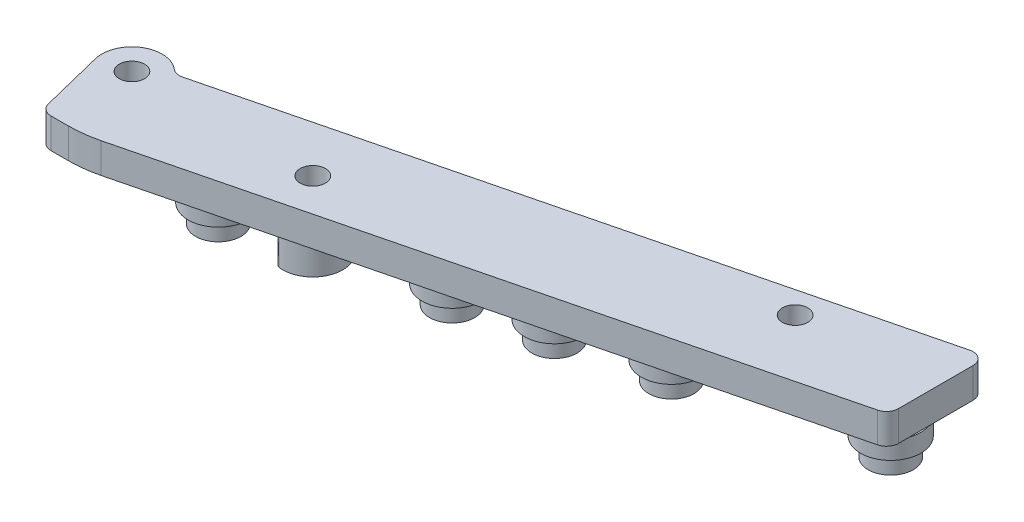
from build123d import *

# Parameters (mm, degrees)
SKETCH1_R           = 2.667
BOSS_EXTRUDE1_DEPTH = 6.35
SKETCH3_R           = 6.35
BOSS_EXTRUDE2_DEPTH = 3.81
SKETCH4_R           = 4.7625
BOSS_EXTRUDE3_DEPTH = 3.81
SKETCH5_R           = 6.35
SKETCH5_R_2         = 2.667
SKETCH5_R_3         = 5.08
SKETCH5_R_4         = 2.723974981
BOSS_EXTRUDE4_DEPTH = 7.62


with BuildPart() as part:
    # Sketch1 → Boss-Extrude1 (new body)
    with BuildSketch(Plane(origin=(0, 0, 0), x_dir=(-1, 0, 0), z_dir=(0, 1, 0))):
        with BuildLine():
            Line((132.859114436, 54.06756661), (1.925518385, 21.422154602))
            ThreePointArc((1.925518385, 21.422154602), (0.538452686, 20.521383604), (0, 18.957603457))
            Line((0, 18.957603457), (0, 3.251051746))
            ThreePointArc((0, 3.251051746), (0.976219853, 1.249504432), (3.154481615, 0.786500601))
            Line((3.154481615, 0.786500601), (135.868185597, 33.875743365))
            ThreePointArc((135.868185597, 33.875743365), (137.061865325, 33.884273202), (138.127619437, 33.346581632))
            ThreePointArc((138.127619437, 33.346581632), (145.587943549, 32.789337046), (148.401377862, 39.7212592))
            Line((148.401377862, 39.7212592), (145.116412217, 52.896536778))
            ThreePointArc((145.116412217, 52.896536778), (144.215641219, 54.283602477), (142.651861072, 54.822055163))
            Line((142.651861072, 54.822055163), (139.003930584, 54.822055163))
            ThreePointArc((139.003930584, 54.822055163), (135.908449262, 54.632727414), (132.859114436, 54.06756661))
        make_face()
        with Locations(Location((142.24, 38.185055163, 0), (0, 0, 90))):
            Circle(SKETCH1_R, mode=Mode.SUBTRACT)
        with Locations(Location((27.94, 12.785055202, 0), (0, 0, 90))):
            Circle(SKETCH1_R, mode=Mode.SUBTRACT)
        with Locations(Location((104.14, 38.185055202, 0), (0, 0, 90))):
            Circle(SKETCH1_R, mode=Mode.SUBTRACT)
    extrude(amount=-BOSS_EXTRUDE1_DEPTH)

    # Sketch3 → Boss-Extrude2 (add)
    with BuildSketch(Plane(origin=(0, -6.35, 0), x_dir=(-1, 0, 0), z_dir=(0, -1, 0))):
        with Locations(Location((6.00871488, -14.586933973, 0), (0, 0, 198.870092131))):
            Circle(SKETCH3_R)
        with Locations(Location((42.976982051, -23.804158196, 0), (0, 0, 270))):
            Circle(SKETCH3_R)
        with Locations(Location((79.945249222, -33.021382418, 0), (0, 0, 270))):
            Circle(SKETCH3_R)
        with Locations(Location((119.378067538, -42.853088255, 0), (0, 0, 270))):
            Circle(SKETCH3_R)
        with Locations(Location((62.693391209, -28.720011114, 0), (0, 0, 270))):
            Circle(SKETCH3_R)
    extrude(amount=BOSS_EXTRUDE2_DEPTH)

    # Sketch4 → Boss-Extrude3 (add)
    with BuildSketch(Plane.XZ.offset(10.16)):
        with Locations(Location((-6.00871488, 14.586933973, 0), (0, 0, 90))):
            Circle(SKETCH4_R)
        with Locations(Location((-42.976982051, 23.804158196, 0), (0, 0, 90))):
            Circle(SKETCH4_R)
        with Locations(Location((-62.693391209, 28.720011114, 0), (0, 0, 90))):
            Circle(SKETCH4_R)
        with Locations(Location((-79.945249222, 33.021382418, 0), (0, 0, 90))):
            Circle(SKETCH4_R)
        with Locations(Location((-119.378067538, 42.853088255, 0), (0, 0, 90))):
            Circle(SKETCH4_R)
    extrude(amount=BOSS_EXTRUDE3_DEPTH)

    # Sketch5 → Boss-Extrude4 (add)
    with BuildSketch(Plane.XZ.offset(6.35)):
        with Locations(Location((-142.24, 38.185055163, 0), (0, 0, 166))):
            Circle(SKETCH5_R)
        with Locations(Location((-142.24, 38.185055163, 0), (0, 0, 90))):
            Circle(SKETCH5_R_2, mode=Mode.SUBTRACT)
        with Locations(Location((-27.94, 12.785055202, 0), (0, 0, 270))):
            Circle(SKETCH5_R_3)
        with Locations(Location((-27.94, 12.785055202, 0), (0, 0, 270))):
            Circle(SKETCH5_R_4, mode=Mode.SUBTRACT)
        with BuildLine():
            Line((-105.580163175, 43.777970545), (-105.715311414, 41.562252701))
            ThreePointArc((-105.715311414, 41.562252701), (-105.443232026, 40.931048752), (-104.773674962, 40.775681582))
            ThreePointArc((-104.773674962, 40.775681582), (-101.589970205, 37.403878498), (-106.115998075, 36.393876649))
            ThreePointArc((-106.115998075, 36.393876649), (-106.757692083, 36.64019843), (-107.336634242, 36.269696613))
            Line((-107.336634242, 36.269696613), (-108.465736097, 34.358466745))
            ThreePointArc((-108.465736097, 34.358466745), (-108.561892576, 33.849199875), (-108.310080465, 33.396221428))
            ThreePointArc((-108.310080465, 33.396221428), (-98.068500487, 36.325110669), (-104.912246263, 44.487922463))
            ThreePointArc((-104.912246263, 44.487922463), (-105.374571656, 44.25371306), (-105.580163175, 43.777970545))
        make_face()
    extrude(amount=BOSS_EXTRUDE4_DEPTH)


solid = part.part
